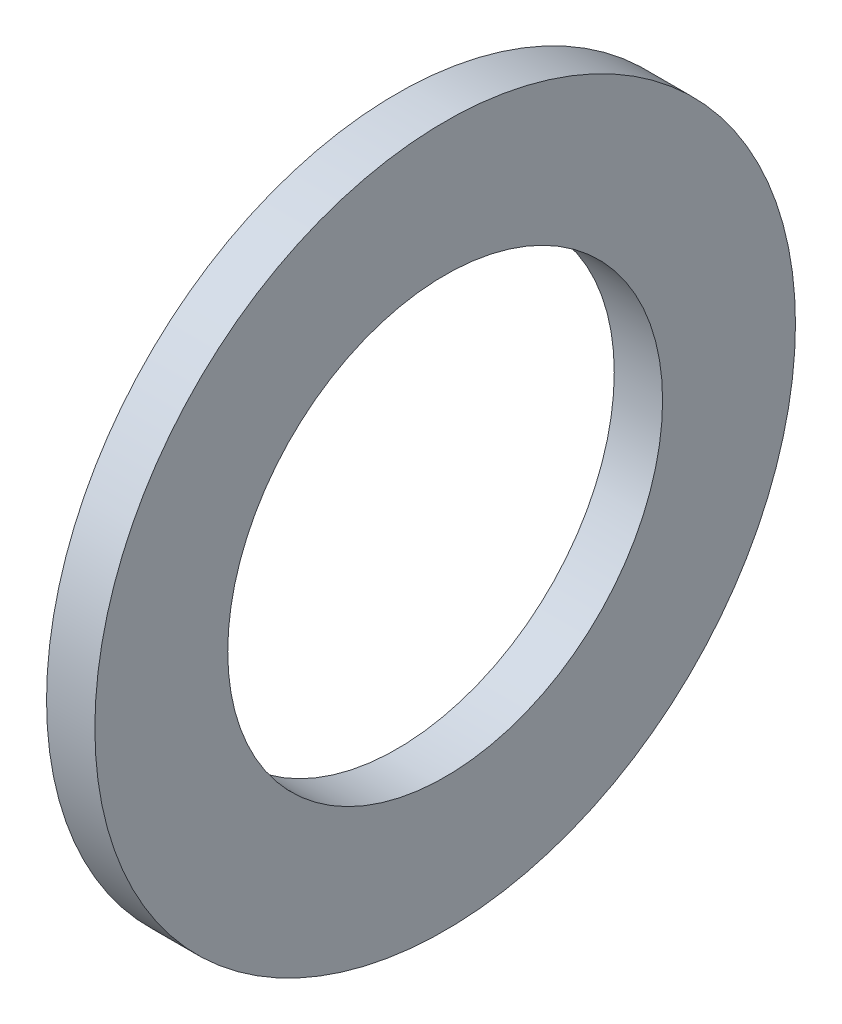
from build123d import *

# Parameters (mm, degrees)
SKETCH1_W = 4
SKETCH1_H = 11


with BuildPart() as part:
    # Sketch1 → Revolve1 (revolve)
    with BuildSketch(Plane(origin=(0, 0, 0), x_dir=(1, 0, 0), z_dir=(0, 1, 0))):
        with Locations((-2, -23.5)):
            Rectangle(SKETCH1_W, SKETCH1_H)
    revolve(axis=Axis((-89.864864865, 0, 0), (1, 0, 0)))


solid = part.part
